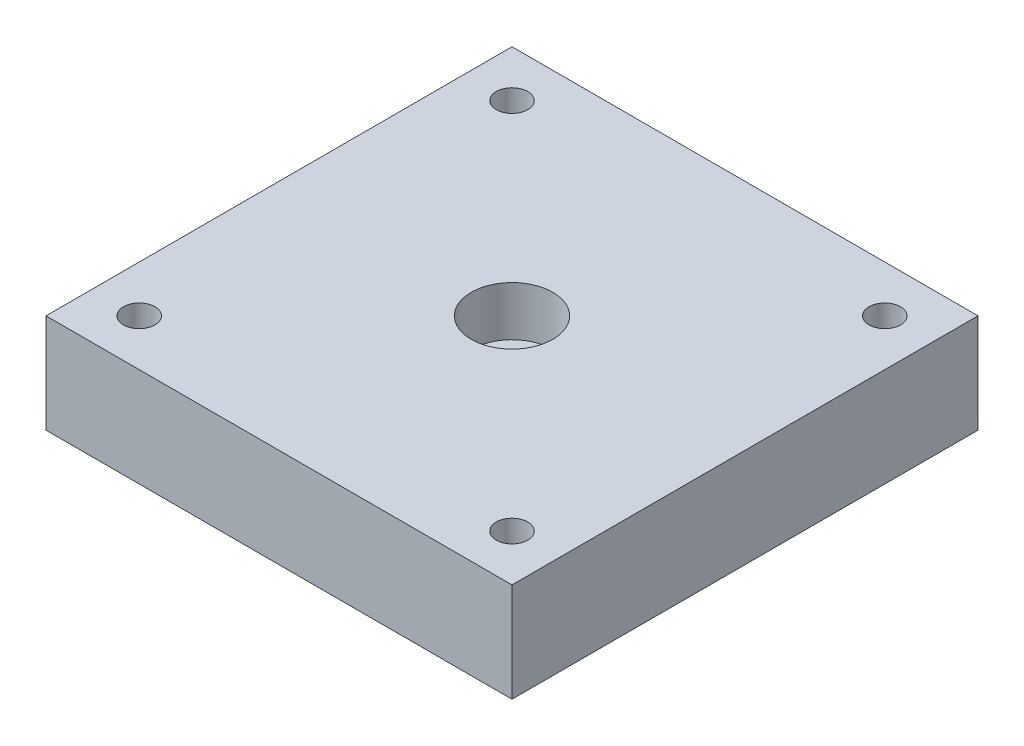
from build123d import *

# Parameters (mm, degrees)
SKETCH1_W           = 40
SKETCH1_H           = 40
BOSS_EXTRUDE1_DEPTH = 8.5
SKETCH2_R           = 1.3525
SKETCH2_R_2         = 2.1
CUT_EXTRUDE1_DEPTH  = 9.5
SKETCH3_R           = 3.5
CUT_EXTRUDE2_DEPTH  = 4.25


with BuildPart() as part:
    # Sketch1 → Boss-Extrude1 (new body)
    with BuildSketch(Plane(origin=(0, 0, 0), x_dir=(1, 0, 0), z_dir=(0, 1, 0))):
        with Locations((20, 20)):
            Rectangle(SKETCH1_W, SKETCH1_H)
    extrude(amount=BOSS_EXTRUDE1_DEPTH)

    # Sketch2 → Cut-Extrude1 (cut, through all)
    with BuildSketch(Plane(origin=(0, 8.5, 0), x_dir=(1, 0, 0), z_dir=(0, 1, 0))):
        with Locations((4, 4)):
            Circle(SKETCH2_R)
        with Locations((36, 4)):
            Circle(SKETCH2_R)
        with Locations((36, 36)):
            Circle(SKETCH2_R)
        with Locations((4, 36)):
            Circle(SKETCH2_R)
        with Locations((20, 20)):
            Circle(SKETCH2_R_2)
    extrude(amount=-CUT_EXTRUDE1_DEPTH, mode=Mode.SUBTRACT)

    # Sketch3 → Cut-Extrude2 (cut)
    with BuildSketch(Plane(origin=(0, 8.5, 0), x_dir=(1, 0, 0), z_dir=(0, 1, 0))):
        with Locations((20, 20)):
            Circle(SKETCH3_R)
    extrude(amount=-CUT_EXTRUDE2_DEPTH, mode=Mode.SUBTRACT)


solid = part.part
